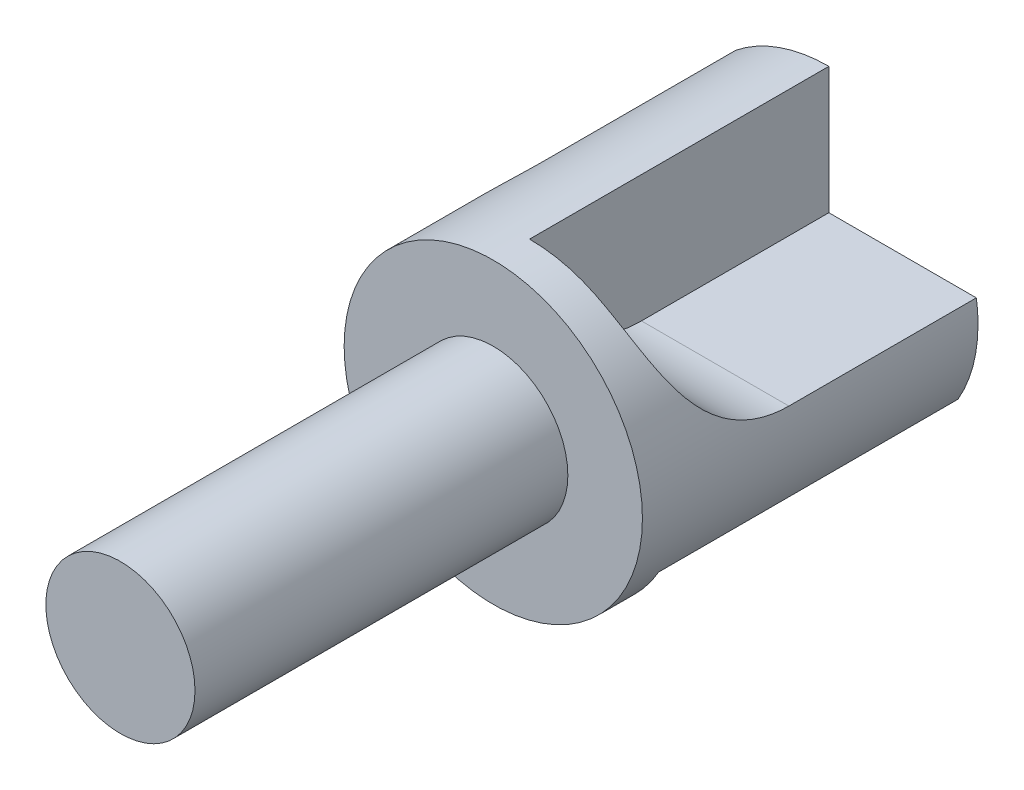
from build123d import *

# Parameters (mm, degrees)
AUSFR_SUNG_DEPTH   = 21
KREISMUSTER1_COUNT = 3


with BuildPart() as part:
    # Skizze1 → Grundk_rper (revolve)
    with BuildSketch(Plane(origin=(0, 0, 0), x_dir=(0, 0, -1), z_dir=(1, 0, 0)), mode=Mode.PRIVATE) as grundk_rper_sk:
        Polygon((95, 0), (95, 20), (50, 20), (50, 10), (0, 10), (0, 0), align=None)
    revolve(grundk_rper_sk.sketch.rotate(Axis((0, 0, 0), (0, 0, -1)), 90), axis=Axis((0, 0, 0), (0, 0, -1)))  # turned: the seam where the file's is

    # Skizze2 → Ausfr_sung (cut, through all)
    with BuildSketch(Plane(origin=(0, 0, 0), x_dir=(0, 0, -1), z_dir=(1, 0, 0))):
        with BuildLine():
            Line((100, 3), (69.866068747, 3))
            ThreePointArc((69.866068747, 3), (59.25946703, 7.393398282), (54.866068747, 18))
            Line((54.866068747, 18), (54.866068747, 23))
            Line((54.866068747, 23), (100, 23))
            Line((100, 23), (100, 3))
        make_face()
    ausfr_sung = extrude(amount=AUSFR_SUNG_DEPTH, mode=Mode.SUBTRACT)

    # Kreismuster1: Ausfr_sung ×3 about axis
    kreismuster1_axis = Axis((0, 0, 0), (0, 0, 1))
    for i in range(1, KREISMUSTER1_COUNT):
        add(ausfr_sung.rotate(kreismuster1_axis, i * 360 / KREISMUSTER1_COUNT), mode=Mode.SUBTRACT)


solid = part.part
